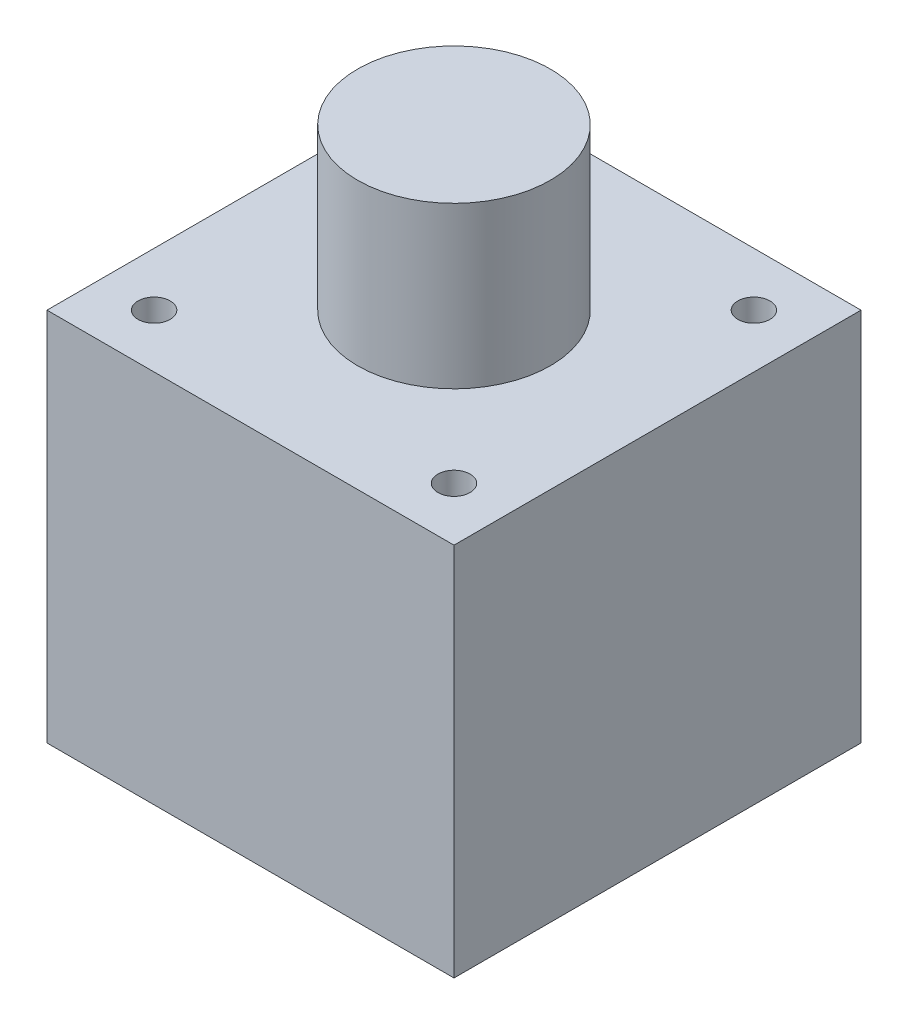
from build123d import *

# Parameters (mm, degrees)
SKETCH1_W             = 38
SKETCH1_H             = 38
BOSS_EXTRUDE1_DEPTH   = 35
SKETCH2_R             = 9
BOSS_EXTRUDE2_DEPTH   = 15
F_3_0MM_DOWEL_HOLE1_D = 3


with BuildPart() as part:
    # Sketch1 → Boss-Extrude1 (new body)
    with BuildSketch(Plane(origin=(0, 0, 0), x_dir=(1, 0, 0), z_dir=(0, 1, 0))):
        Rectangle(SKETCH1_W, SKETCH1_H)
    extrude(amount=BOSS_EXTRUDE1_DEPTH)

    # Sketch2 → Boss-Extrude2 (add)
    with BuildSketch(Plane(origin=(0, 35, 0), x_dir=(1, 0, 0), z_dir=(0, 1, 0))):
        Circle(SKETCH2_R)
    extrude(amount=BOSS_EXTRUDE2_DEPTH)

    # Ø3.0mm Dowel Hole1 (through all)
    with Locations(Plane(origin=(0, 0, 0), x_dir=(-1, 0, 0), z_dir=(0, -1, 0))):
        with Locations((-14, -14), (-14, 14), (14, 14), (14, -14)):
            Hole(F_3_0MM_DOWEL_HOLE1_D / 2)


solid = part.part
